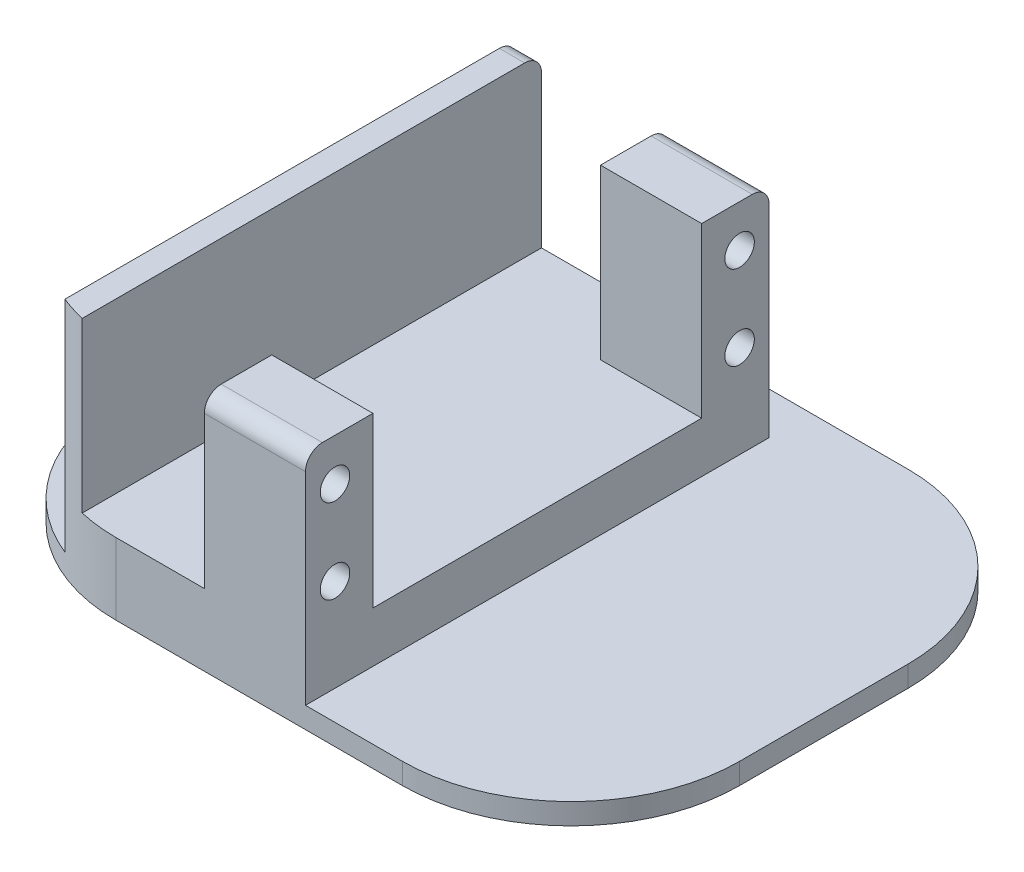
from build123d import *

# Parameters (mm, degrees)
ESQUISSE1_W             = 74
ESQUISSE1_H             = 60
BOSS_EXTRU_1_DEPTH      = 2.5
ESQUISSE2_W             = 30
ESQUISSE2_H             = 55
BOSS_EXTRU_2_DEPTH      = 6
ESQUISSE4_W             = 12
ESQUISSE4_H             = 8
BOSS_EXTRU_3_DEPTH      = 20
ESQUISSE5_R             = 1.75
ENL_V_MAT_EXTRU_1_DEPTH = 20
ESQUISSE6_R             = 2.95
BOSS_EXTRU_4_DEPTH      = 5
CONG_1_R                = 1
CONG_2_R                = 20
CONG_3_R                = 2


with BuildPart() as part:
    # Esquisse1 → Boss.-Extru.1 (new body)
    with BuildSketch(Plane(origin=(0, 0, 0), x_dir=(1, 0, 0), z_dir=(0, 1, 0))):
        with Locations((37, 30)):
            Rectangle(ESQUISSE1_W, ESQUISSE1_H)
    extrude(amount=BOSS_EXTRU_1_DEPTH)

    # Esquisse2 → Boss.-Extru.2 (add)
    with BuildSketch(Plane(origin=(0, 2.5, 0), x_dir=(1, 0, 0), z_dir=(0, 1, 0))):
        with Locations((27.5, 27.5)):
            Rectangle(ESQUISSE2_W, ESQUISSE2_H)
    extrude(amount=BOSS_EXTRU_2_DEPTH)

    # Esquisse4 → Boss.-Extru.3 (add)
    with BuildSketch(Plane(origin=(0, 8.5, 0), x_dir=(1, 0, 0), z_dir=(0, 1, 0))):
        with Locations((36.5, 51)):
            Rectangle(ESQUISSE4_W, ESQUISSE4_H)
        Polygon((12.5, 55), (12.5, 52), (12.5, 13), (12.5, 0), (15.5, 0), (15.5, 13), (15.5, 52), (15.5, 55), align=None)
        with Locations((36.5, 4)):
            Rectangle(ESQUISSE4_W, ESQUISSE4_H)
    extrude(amount=BOSS_EXTRU_3_DEPTH)

    # Esquisse5 → Enlèv. mat.-Extru.1 (cut)
    with BuildSketch(Plane(origin=(42.5, 0, 0), x_dir=(0, 0, -1), z_dir=(1, 0, 0))):
        with Locations((3.5, 23.5)):
            Circle(ESQUISSE5_R)
        with Locations((3.5, 13.5)):
            Circle(ESQUISSE5_R)
        with Locations((51.5, 23.5)):
            Circle(ESQUISSE5_R)
        with Locations((51.5, 13.5)):
            Circle(ESQUISSE5_R)
    extrude(amount=-ENL_V_MAT_EXTRU_1_DEPTH, mode=Mode.SUBTRACT)

    # Esquisse6 → Boss.-Extru.4 (add)
    with BuildSketch(Plane.ZY.offset(-12.5)):
        with Locations((-18, 18.5)):
            Circle(ESQUISSE6_R)
    extrude(amount=BOSS_EXTRU_4_DEPTH)

    # Congé1
    cong_1_edges = [part.edges().sort_by_distance(p)[0] for p in [
        (12.5, 18.5, -20.95),
    ]]
    fillet(cong_1_edges, radius=CONG_1_R)

    # Congé2
    cong_2_edges = [part.edges().sort_by_distance(p)[0] for p in [
        (74, 1.25, -60),
        (74, 1.25, 0),
        (0, 1.25, 0),
        (0, 1.25, -60),
    ]]
    fillet(cong_2_edges, radius=CONG_2_R)

    # Congé3
    cong_3_edges = [part.edges().sort_by_distance(p)[0] for p in [
        (36.5, 28.5, 0),
        (14, 28.5, -55),
        (36.5, 28.5, -55),
    ]]
    fillet(cong_3_edges, radius=CONG_3_R)


solid = part.part
